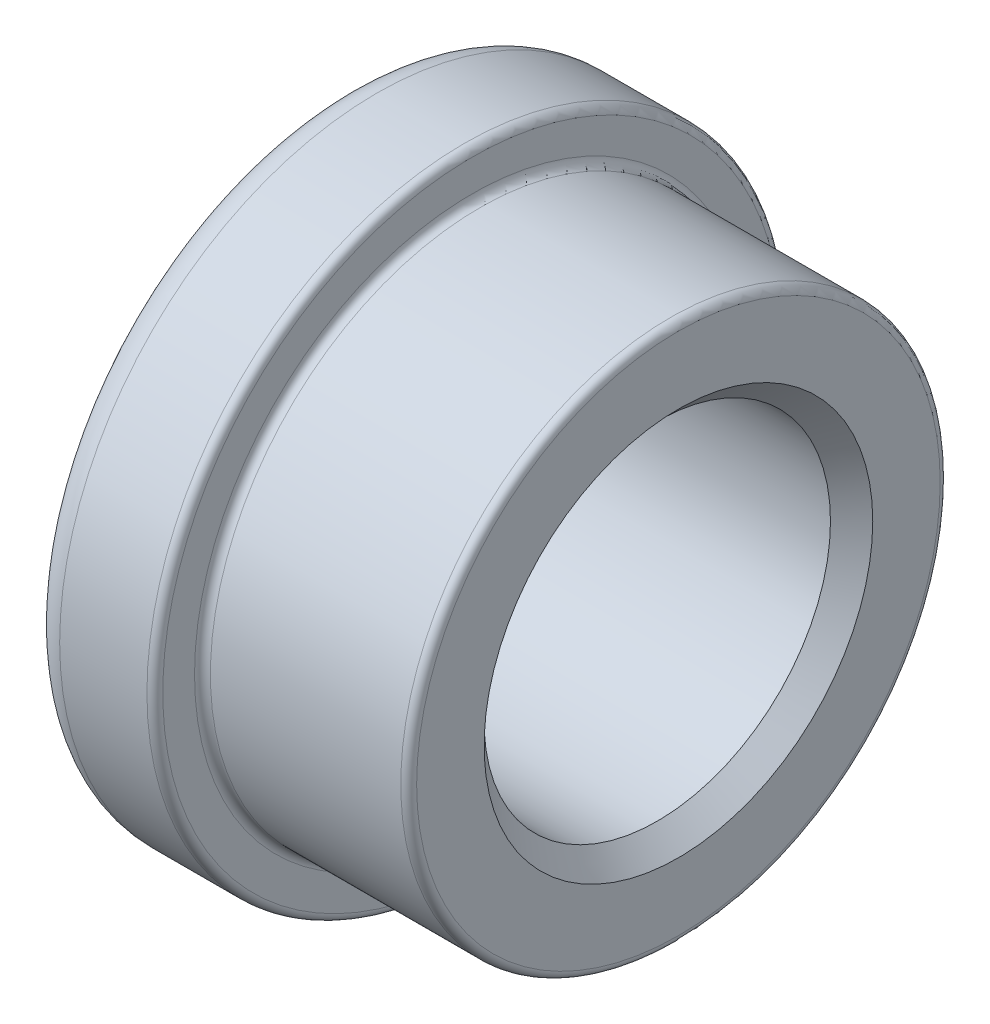
from build123d import *


with BuildPart() as part:
    # Sketch1 → Base-Revolve (revolve)
    with BuildSketch(Plane.XY):
        with BuildLine():
            Line((0, 12.25), (0, 16.5))
            ThreePointArc((0, 16.5), (-0.146446609, 16.853553391), (-0.5, 17))
            Line((-0.5, 17), (-12.5, 17))
            ThreePointArc((-12.5, 17), (-12.853553391, 17.146446609), (-13, 17.5))
            Line((-13, 17.5), (-13, 19.5))
            ThreePointArc((-13, 19.5), (-13.146446609, 19.853553391), (-13.5, 20))
            Line((-13.5, 20), (-19, 20))
            ThreePointArc((-19, 20), (-20.414213562, 19.414213562), (-21, 18))
            Line((-21, 18), (-21, 12.25))
            Line((-21, 12.25), (-19.6675, 10.9175))
            Line((-19.6675, 10.9175), (-1.3325, 10.9175))
            Line((-1.3325, 10.9175), (0, 12.25))
        make_face()
    revolve(axis=Axis((0, 0, 0), (-1, 0, 0)))


solid = part.part
